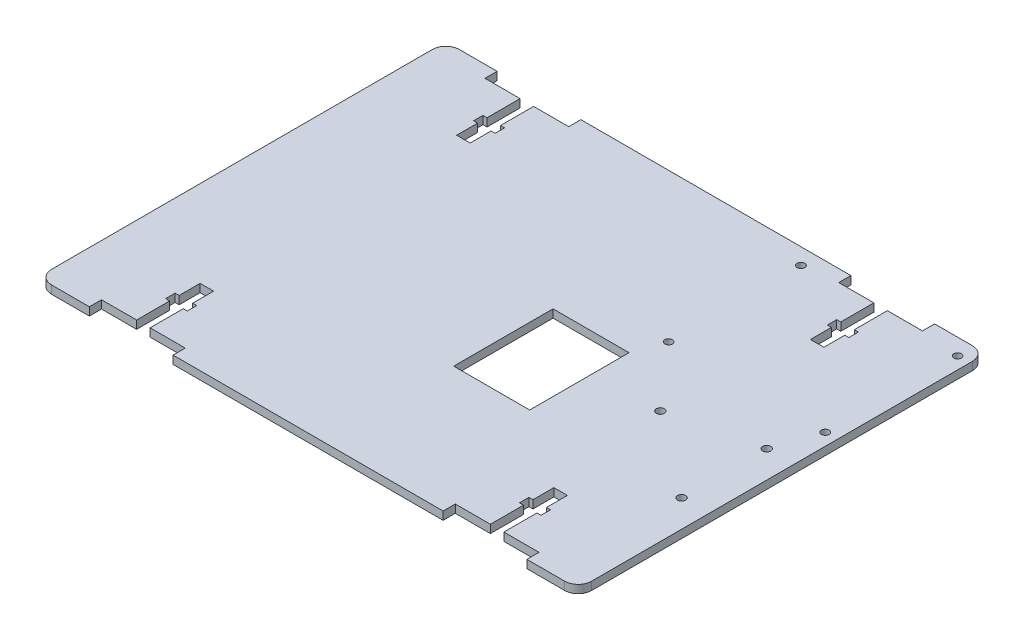
from build123d import *

# Parameters (mm, degrees)
SKETCH1_W           = 200
SKETCH1_H           = 151
BOSS_EXTRUDE1_DEPTH = 3
SKETCH2_W           = 28.1297743
SKETCH2_H           = 36.772110208
SKETCH2_R           = 1.5
SKETCH2_R_2         = 1.4
CUT_EXTRUDE2_DEPTH  = 4
FILLET1_R           = 5


with BuildPart() as part:
    # Sketch1 → Boss-Extrude1 (new body)
    with BuildSketch(Plane(origin=(0, 0, 0), x_dir=(1, 0, 0), z_dir=(0, 1, 0))):
        Rectangle(SKETCH1_W, SKETCH1_H)
    extrude(amount=BOSS_EXTRUDE1_DEPTH)

    # Sketch2 → Cut-Extrude2 (cut, through all)
    with BuildSketch(Plane(origin=(0, 3, 0), x_dir=(1, 0, 0), z_dir=(0, 1, 0))):
        Polygon((-50, 75.5), (-81, 75.5), (-81, 71), (-68, 71), (-68, 58.75), (-69.5, 58.75), (-69.5, 55.25), (-68, 55.25), (-68, 47.5), (-63, 47.5), (-63, 55.25), (-61.5, 55.25), (-61.5, 58.75), (-63, 58.75), (-63, 71), (-50, 71), align=None)
        Polygon((50, 71), (63, 71), (63, 58.75), (61.5, 58.75), (61.5, 55.25), (63, 55.25), (63, 47.5), (68, 47.5), (68, 55.25), (69.5, 55.25), (69.5, 58.75), (68, 58.75), (68, 71), (81, 71), (81, 75.5), (50, 75.5), align=None)
        Polygon((50, -75.5), (81, -75.5), (81, -71), (68, -71), (68, -58.75), (69.5, -58.75), (69.5, -55.25), (68, -55.25), (68, -47.5), (63, -47.5), (63, -55.25), (61.5, -55.25), (61.5, -58.75), (63, -58.75), (63, -71), (50, -71), align=None)
        Polygon((-50, -71), (-63, -71), (-63, -58.75), (-61.5, -58.75), (-61.5, -55.25), (-63, -55.25), (-63, -47.5), (-68, -47.5), (-68, -55.25), (-69.5, -55.25), (-69.5, -58.75), (-68, -58.75), (-68, -71), (-81, -71), (-81, -75.5), (-50, -75.5), align=None)
        with Locations((19.572588651, -8.701882989)):
            Rectangle(SKETCH2_W, SKETCH2_H)
        with Locations((89.92, -27.12)):
            Circle(SKETCH2_R)
        with Locations((89.92, 4.39)):
            Circle(SKETCH2_R)
        with Locations((58.16, -3.22)):
            Circle(SKETCH2_R)
        with Locations((95.5, 20.5)):
            Circle(SKETCH2_R_2)
        with Locations((37.5, 20.5)):
            Circle(SKETCH2_R_2)
        with Locations((37.5, 69.5)):
            Circle(SKETCH2_R_2)
        with Locations((95.5, 69.5)):
            Circle(SKETCH2_R_2)
    extrude(amount=-CUT_EXTRUDE2_DEPTH, mode=Mode.SUBTRACT)

    # Fillet1
    fillet1_edges = [part.edges().sort_by_distance(p)[0] for p in [
        (100, 1.5, 75.5),
        (-100, 1.5, 75.5),
        (-100, 1.5, -75.5),
        (100, 1.5, -75.5),
    ]]
    fillet(fillet1_edges, radius=FILLET1_R)


solid = part.part
